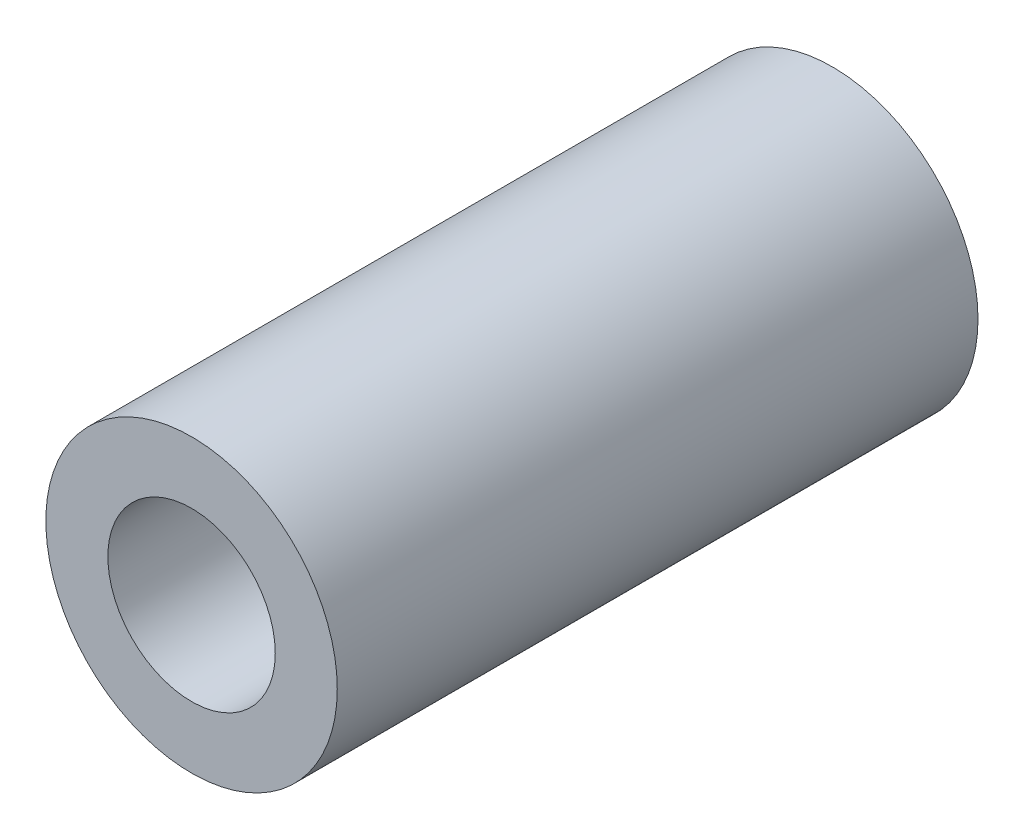
from build123d import *

# Parameters (mm, degrees)
SKETCH1_R           = 7.05
SKETCH1_R_2         = 4.05
BOSS_EXTRUDE1_DEPTH = 31


with BuildPart() as part:
    # Sketch1 → Boss-Extrude1 (new body)
    with BuildSketch(Plane.XY):
        Circle(SKETCH1_R)
        Circle(SKETCH1_R_2, mode=Mode.SUBTRACT)
    extrude(amount=BOSS_EXTRUDE1_DEPTH)


solid = part.part
